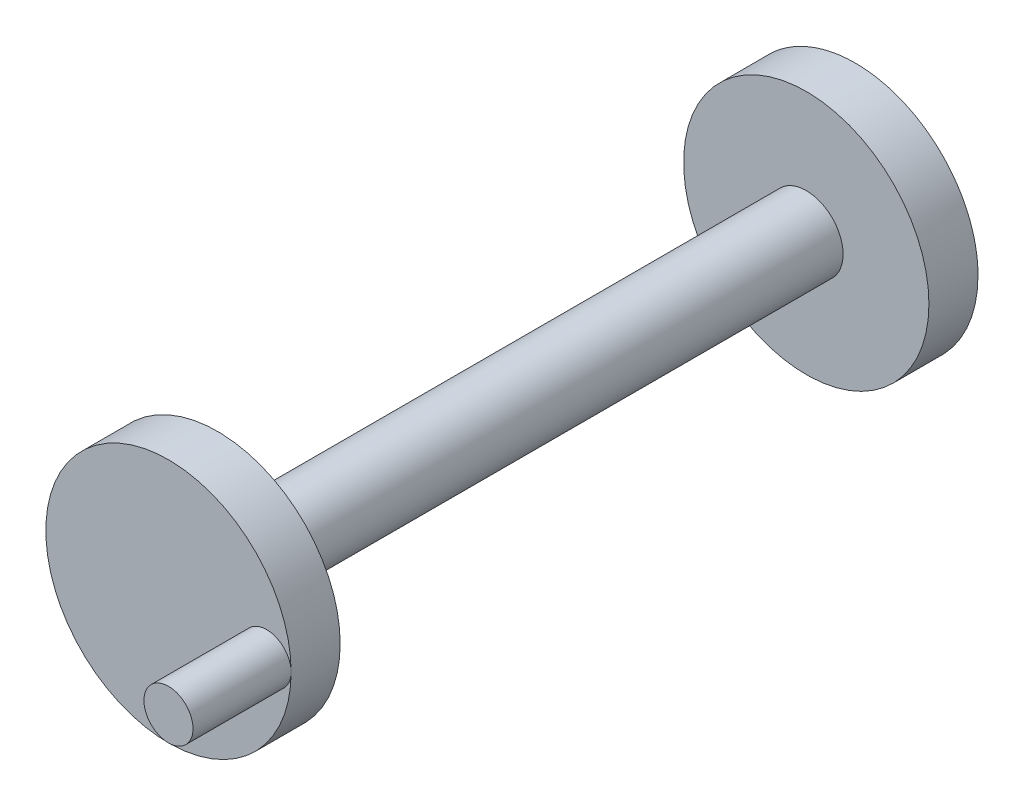
from build123d import *

# Parameters (mm, degrees)
SKETCH1_R           = 2.5
BOSS_EXTRUDE1_DEPTH = 1
SKETCH1_3_R         = 0.75
BOSS_EXTRUDE2_DEPTH = 12
BOSS_EXTRUDE4_START = 1
SKETCH1_5_R         = 0.5
BOSS_EXTRUDE4_DEPTH = 2
BOSS_EXTRUDE6_START = -13
SKETCH1_7_R         = 2.5
BOSS_EXTRUDE6_DEPTH = 1
BOSS_EXTRUDE7_START = -13
SKETCH1_8_R         = 0.5
BOSS_EXTRUDE7_DEPTH = 2


with BuildPart() as part:
    # Sketch1 → Boss-Extrude1 (new body)
    with BuildSketch(Plane.XY):
        Circle(SKETCH1_R)
    extrude(amount=BOSS_EXTRUDE1_DEPTH)

    # Sketch1_3 → Boss-Extrude2 (add)
    with BuildSketch(Plane.XY):
        Circle(SKETCH1_3_R)
    extrude(amount=-BOSS_EXTRUDE2_DEPTH)

    # Sketch1_5 → Boss-Extrude4 (add)
    with BuildSketch(Plane.XY.offset(BOSS_EXTRUDE4_START)):
        with Locations((2, 0)):
            Circle(SKETCH1_5_R)
    extrude(amount=BOSS_EXTRUDE4_DEPTH)

    # Sketch1_7 → Boss-Extrude6 (add)
    with BuildSketch(Plane.XY.offset(BOSS_EXTRUDE6_START)):
        Circle(SKETCH1_7_R)
    extrude(amount=BOSS_EXTRUDE6_DEPTH)

    # Sketch1_8 → Boss-Extrude7 (add)
    with BuildSketch(Plane.XY.offset(BOSS_EXTRUDE7_START)):
        with Locations((-2, 0)):
            Circle(SKETCH1_8_R)
    extrude(amount=-BOSS_EXTRUDE7_DEPTH)


solid = part.part
